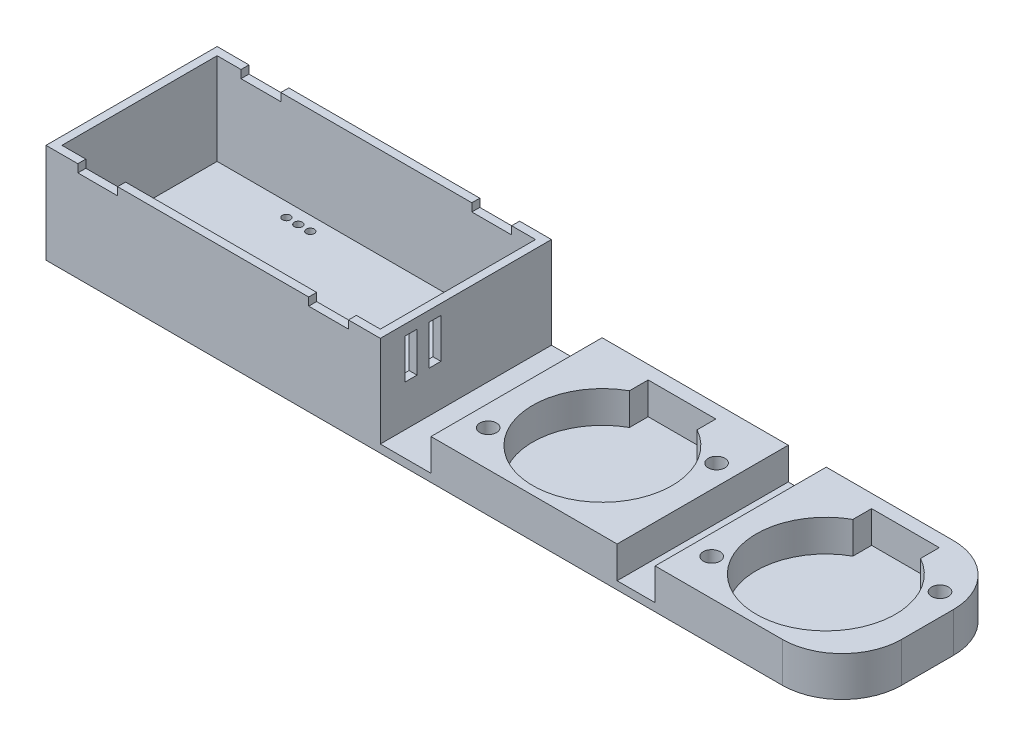
from build123d import *

# Parameters (mm, degrees)
SKETCH1_W           = 200
SKETCH1_H           = 43
BOSS_EXTRUDE1_DEPTH = 25
SKETCH2_W           = 80
SKETCH2_H           = 39
CUT_EXTRUDE1_DEPTH  = 23
SKETCH3_W           = 28
SKETCH3_H           = 14
BOSS_EXTRUDE2_DEPTH = 8
SKETCH4_W           = 14
SKETCH4_H           = 2
BOSS_EXTRUDE3_DEPTH = 2.5
SKETCH5_W           = 14
SKETCH5_H           = 2
BOSS_EXTRUDE4_DEPTH = 2.5
SKETCH6_R           = 1
CUT_EXTRUDE2_DEPTH  = 2
SKETCH7_W           = 116
SKETCH7_H           = 43
CUT_EXTRUDE3_DEPTH  = 23
SKETCH8_W           = 46.953712071
SKETCH8_H           = 43
SKETCH8_R           = 2.1
BOSS_EXTRUDE6_DEPTH = 8
SKETCH9_W           = 10
SKETCH9_H           = 2
CUT_EXTRUDE4_DEPTH  = 61
SKETCH10_W          = 46.769233888
SKETCH10_H          = 43
SKETCH10_R          = 2.1
BOSS_EXTRUDE7_DEPTH = 8
SKETCH11_W          = 3
SKETCH11_H          = 10
CUT_EXTRUDE5_DEPTH  = 8
FILLET1_R           = 15
FILLET2_R           = 15


with BuildPart() as part:
    # Sketch1 → Boss-Extrude1 (new body)
    with BuildSketch(Plane(origin=(0, 0, 0), x_dir=(1, 0, 0), z_dir=(0, 1, 0))):
        with Locations((100, 21.5)):
            Rectangle(SKETCH1_W, SKETCH1_H)
    extrude(amount=BOSS_EXTRUDE1_DEPTH)

    # Sketch2 → Cut-Extrude1 (cut)
    with BuildSketch(Plane(origin=(0, 25, 0), x_dir=(1, 0, 0), z_dir=(0, 1, 0))):
        with Locations((42, 21.5)):
            Rectangle(SKETCH2_W, SKETCH2_H)
    extrude(amount=-CUT_EXTRUDE1_DEPTH, mode=Mode.SUBTRACT)

    # Sketch3 → Boss-Extrude2 (add)
    with BuildSketch(Plane.XZ):
        with Locations((25.914586037, -21)):
            Rectangle(SKETCH3_W, SKETCH3_H)
    extrude(amount=BOSS_EXTRUDE2_DEPTH)

    # Sketch4 → Boss-Extrude3 (add)
    with BuildSketch(Plane(origin=(39.914586037, 0, 0), x_dir=(0, 0, -1), z_dir=(1, 0, 0))):
        with Locations((21, -7)):
            Rectangle(SKETCH4_W, SKETCH4_H)
    extrude(amount=BOSS_EXTRUDE3_DEPTH)

    # Sketch5 → Boss-Extrude4 (add)
    with BuildSketch(Plane.ZY.offset(-11.914586037)):
        with Locations((-21, -7)):
            Rectangle(SKETCH5_W, SKETCH5_H)
    extrude(amount=BOSS_EXTRUDE4_DEPTH)

    # Sketch6 → Cut-Extrude2 (cut)
    with BuildSketch(Plane.XZ):
        with Locations(Location((25.914586037, -37.49, 0), (0, 0, 270))):
            Circle(SKETCH6_R)
        with Locations(Location((28.914586037, -37.49, 0), (0, 0, 270))):
            Circle(SKETCH6_R)
        with Locations(Location((22.914586037, -37.49, 0), (0, 0, 270))):
            Circle(SKETCH6_R)
    extrude(amount=-CUT_EXTRUDE2_DEPTH, mode=Mode.SUBTRACT)

    # Sketch7 → Cut-Extrude3 (cut)
    with BuildSketch(Plane(origin=(0, 25, 0), x_dir=(1, 0, 0), z_dir=(0, 1, 0))):
        with Locations((142, 21.5)):
            Rectangle(SKETCH7_W, SKETCH7_H)
    extrude(amount=-CUT_EXTRUDE3_DEPTH, mode=Mode.SUBTRACT)

    # Sketch8 → Boss-Extrude6 (add)
    with BuildSketch(Plane(origin=(0, 2, 0), x_dir=(1, 0, 0), z_dir=(0, 1, 0))):
        with Locations((176.523143965, 21.5)):
            Rectangle(SKETCH8_W, SKETCH8_H)
        with BuildLine():
            Line((167.769501391, 39.672770255), (184.769501391, 39.672770255))
            Line((184.769501391, 39.672770255), (184.769501391, 34.969828795))
            ThreePointArc((184.769501391, 34.969828795), (187.225820525, 33.318614715), (189.368743796, 31.277073268))
            Line((189.368743796, 31.277073268), (192.70603487, 33.203859168))
            ThreePointArc((192.70603487, 33.203859168), (197.487123783, 31.922770255), (196.20603487, 27.141681341))
            Line((196.20603487, 27.141681341), (192.868743796, 25.214895441))
            ThreePointArc((192.868743796, 25.214895441), (193.542844178, 22.480194155), (193.769501391, 19.672770255))
            ThreePointArc((193.769501391, 19.672770255), (182.474872367, 3.309904642), (163.170258986, 8.068467242))
            Line((163.170258986, 8.068467242), (159.832967911, 6.141681341))
            ThreePointArc((159.832967911, 6.141681341), (155.051878998, 7.422770255), (156.332967911, 12.203859168))
            Line((156.332967911, 12.203859168), (159.670258986, 14.130645068))
            ThreePointArc((159.670258986, 14.130645068), (159.958128459, 26.012258646), (167.769501391, 34.969828795))
            Line((167.769501391, 34.969828795), (167.769501391, 39.672770255))
        make_face(mode=Mode.SUBTRACT)
        with BuildLine():
            Line((192.70603487, 33.203859168), (189.368743796, 31.277073268))
            ThreePointArc((189.368743796, 31.277073268), (191.424945957, 28.422770255), (192.868743796, 25.214895441))
            Line((192.868743796, 25.214895441), (196.20603487, 27.141681341))
            ThreePointArc((196.20603487, 27.141681341), (197.487123783, 31.922770255), (192.70603487, 33.203859168))
        make_face()
        with Locations(Location((194.45603487, 30.172770255, 0), (0, 0, 270))):
            Circle(SKETCH8_R, mode=Mode.SUBTRACT)
        with BuildLine():
            ThreePointArc((163.170258986, 8.068467242), (161.114056824, 10.922770255), (159.670258986, 14.130645068))
            Line((159.670258986, 14.130645068), (156.332967911, 12.203859168))
            ThreePointArc((156.332967911, 12.203859168), (155.051878998, 7.422770255), (159.832967911, 6.141681341))
            Line((159.832967911, 6.141681341), (163.170258986, 8.068467242))
        make_face()
        with Locations(Location((158.082967911, 9.172770255, 0), (0, 0, 270))):
            Circle(SKETCH8_R, mode=Mode.SUBTRACT)
    extrude(amount=BOSS_EXTRUDE6_DEPTH)

    # Sketch9 → Cut-Extrude4 (cut)
    with BuildSketch(Plane.XY):
        with Locations((13, 24)):
            Rectangle(SKETCH9_W, SKETCH9_H)
        with Locations((71, 24)):
            Rectangle(SKETCH9_W, SKETCH9_H)
    extrude(amount=-CUT_EXTRUDE4_DEPTH, mode=Mode.SUBTRACT)

    # Sketch10 → Boss-Extrude7 (add)
    with BuildSketch(Plane(origin=(0, 2, 0), x_dir=(1, 0, 0), z_dir=(0, 1, 0))):
        with Locations((120.116777129, 21.5)):
            Rectangle(SKETCH10_W, SKETCH10_H)
        with BuildLine():
            Line((111.703601521, 39.593697937), (128.703601521, 39.593697937))
            Line((128.703601521, 39.593697937), (128.703601521, 34.890756478))
            ThreePointArc((128.703601521, 34.890756478), (131.159920655, 33.239542397), (133.302843926, 31.19800095))
            Line((133.302843926, 31.19800095), (136.640135, 33.12478685))
            ThreePointArc((136.640135, 33.12478685), (141.421223914, 31.843697937), (140.140135, 27.062609024))
            Line((140.140135, 27.062609024), (136.802843926, 25.135823124))
            ThreePointArc((136.802843926, 25.135823124), (137.476944308, 22.401121838), (137.703601521, 19.593697937))
            ThreePointArc((137.703601521, 19.593697937), (126.408972497, 3.230832325), (107.104359116, 7.989394924))
            Line((107.104359116, 7.989394924), (103.767068041, 6.062609024))
            ThreePointArc((103.767068041, 6.062609024), (98.985979128, 7.343697937), (100.267068041, 12.12478685))
            Line((100.267068041, 12.12478685), (103.604359116, 14.051572751))
            ThreePointArc((103.604359116, 14.051572751), (103.892228589, 25.933186329), (111.703601521, 34.890756478))
            Line((111.703601521, 34.890756478), (111.703601521, 39.593697937))
        make_face(mode=Mode.SUBTRACT)
        with BuildLine():
            Line((136.640135, 33.12478685), (133.302843926, 31.19800095))
            ThreePointArc((133.302843926, 31.19800095), (135.359046087, 28.343697937), (136.802843926, 25.135823124))
            Line((136.802843926, 25.135823124), (140.140135, 27.062609024))
            ThreePointArc((140.140135, 27.062609024), (141.421223914, 31.843697937), (136.640135, 33.12478685))
        make_face()
        with Locations(Location((138.390135, 30.093697937, 0), (0, 0, 270))):
            Circle(SKETCH10_R, mode=Mode.SUBTRACT)
        with BuildLine():
            ThreePointArc((107.104359116, 7.989394924), (105.048156955, 10.843697937), (103.604359116, 14.051572751))
            Line((103.604359116, 14.051572751), (100.267068041, 12.12478685))
            ThreePointArc((100.267068041, 12.12478685), (98.985979128, 7.343697937), (103.767068041, 6.062609024))
            Line((103.767068041, 6.062609024), (107.104359116, 7.989394924))
        make_face()
        with Locations(Location((102.017068041, 9.093697937, 0), (0, 0, 270))):
            Circle(SKETCH10_R, mode=Mode.SUBTRACT)
    extrude(amount=BOSS_EXTRUDE7_DEPTH)

    # Sketch11 → Cut-Extrude5 (cut)
    with BuildSketch(Plane(origin=(84, 0, 0), x_dir=(0, 0, -1), z_dir=(1, 0, 0))):
        with Locations((13.721629554, 17.383252488)):
            Rectangle(SKETCH11_W, SKETCH11_H)
        with Locations((7.721629554, 17.383252488)):
            Rectangle(SKETCH11_W, SKETCH11_H)
    extrude(amount=-CUT_EXTRUDE5_DEPTH, mode=Mode.SUBTRACT)

    # Fillet1
    fillet1_edges = [part.edges().sort_by_distance(p)[0] for p in [
        (200, 5, 0),
    ]]
    fillet(fillet1_edges, radius=FILLET1_R)

    # Fillet2
    fillet2_edges = [part.edges().sort_by_distance(p)[0] for p in [
        (200, 5, -43),
    ]]
    fillet(fillet2_edges, radius=FILLET2_R)


solid = part.part
